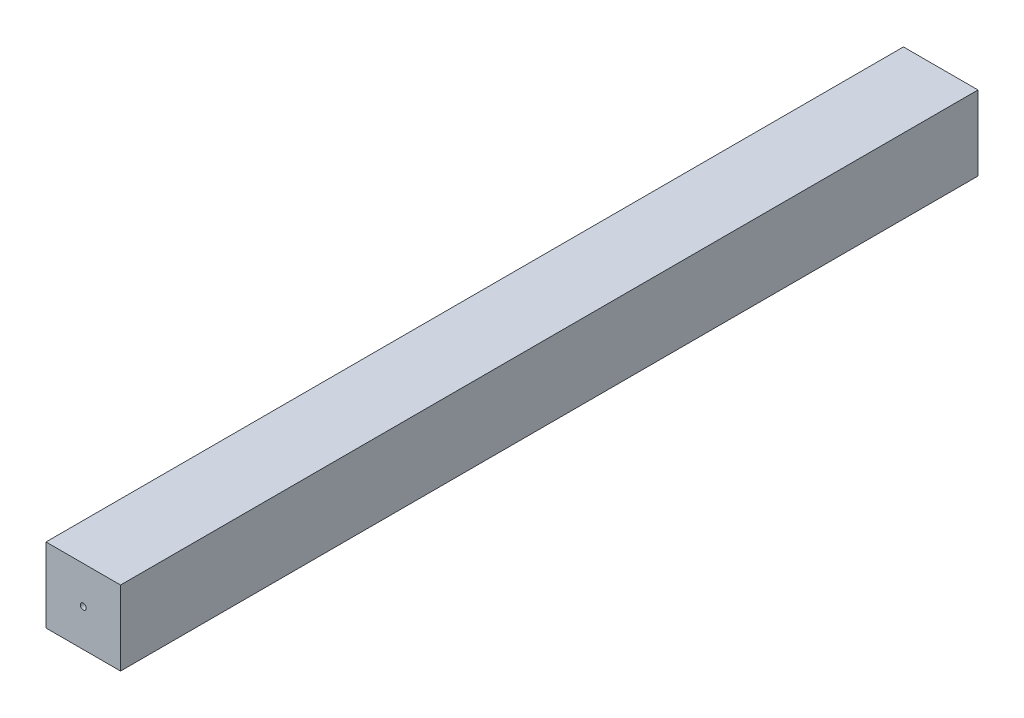
from build123d import *

# Parameters (mm, degrees)
ESQUISSE1_W             = 44
ESQUISSE1_H             = 44
BOSS_EXTRU_1_DEPTH      = 506
ESQUISSE2_R             = 1.75
ENL_V_MAT_EXTRU_1_DEPTH = 60
ESQUISSE3_R             = 1.75
ENL_V_MAT_EXTRU_2_DEPTH = 60


with BuildPart() as part:
    # Esquisse1 → Boss.-Extru.1 (new body)
    with BuildSketch(Plane.XY):
        Rectangle(ESQUISSE1_W, ESQUISSE1_H)
    extrude(amount=BOSS_EXTRU_1_DEPTH)

    # Esquisse2 → Enlèv. mat.-Extru.1 (cut)
    with BuildSketch(Plane(origin=(0, 0, 0), x_dir=(-1, 0, 0), z_dir=(0, 0, -1))):
        Circle(ESQUISSE2_R)
    extrude(amount=-ENL_V_MAT_EXTRU_1_DEPTH, mode=Mode.SUBTRACT)

    # Esquisse3 → Enlèv. mat.-Extru.2 (cut)
    with BuildSketch(Plane.XY.offset(506)):
        Circle(ESQUISSE3_R)
    extrude(amount=-ENL_V_MAT_EXTRU_2_DEPTH, mode=Mode.SUBTRACT)


solid = part.part
